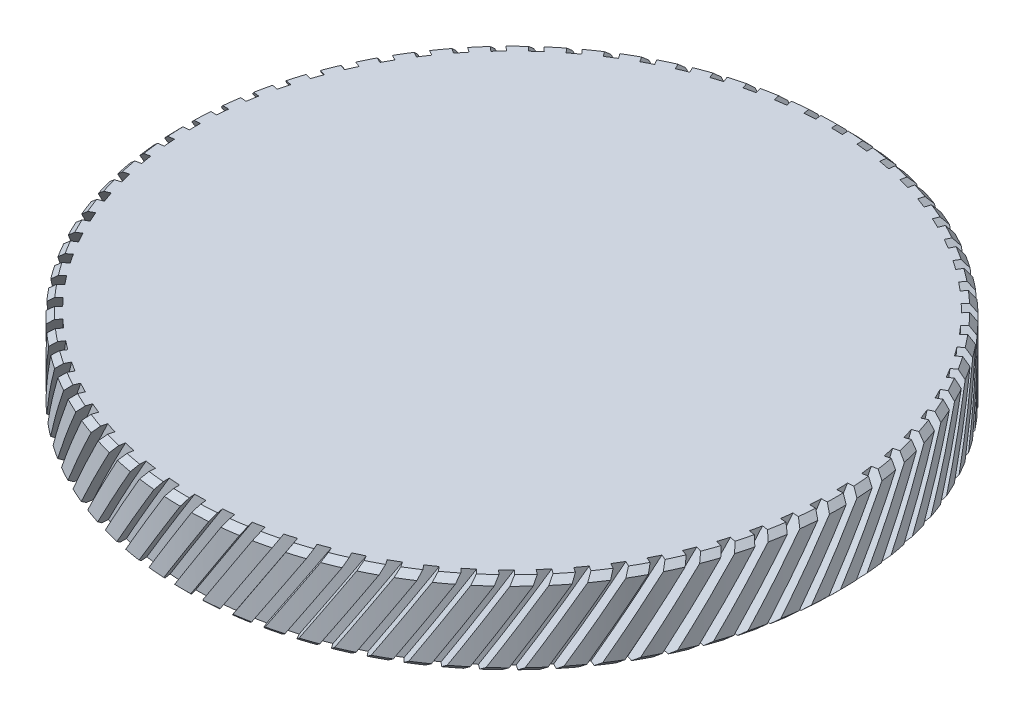
from build123d import *

# Parameters (mm, degrees)
CHAMFER_1_SIZE           = 0.5
CUT_EXTRUDE_1_REACH      = 73.782
CUT_EXTRUDE_1_END_RADIUS = 27
CUT_EXTRUDE_START        = 30
PATTERN_CIRCULAR_1_COUNT = 75


with BuildPart() as part:
    # 草图1 → 旋转1 (revolve)
    with BuildSketch(Plane.XY, mode=Mode.PRIVATE) as revolve_1_sk:
        Polygon((25.1, -8.830884482), (26.1, -8.830884482), (26.1, -7.830884482), (0, -7.830884482), (0, -6.330884482), (28, -6.330884482), (28, -13.330884482), (25.1, -13.330884482), align=None)
    revolve(revolve_1_sk.sketch.rotate(Axis((0, 46.02073106, 0), (0, -1, 0)), 90), axis=Axis((0, 46.02073106, 0), (0, -1, 0)))

    # 倒角1
    chamfer_1_edges = [part.edges().sort_by_distance(p)[0] for p in [
        (0, -6.330884482, -28),
        (0, -13.330884482, -28),
    ]]
    chamfer(chamfer_1_edges, length=CHAMFER_1_SIZE)

    # 切除-拉伸1: up to this cylinder (the profile starts outside it)
    cut_extrude_1_end = Plane(origin=(0, -8.265312, 0), z_dir=(0, 1, 0)) * Cylinder(CUT_EXTRUDE_1_END_RADIUS, 202.564, mode=Mode.PRIVATE)
    # 草图2 → 切除-拉伸1 (cut, up to the surface)
    with BuildSketch(Plane.XY.offset(CUT_EXTRUDE_START), mode=Mode.PRIVATE) as cut_extrude_1_sk1:
        Polygon((0, -2.775948505), (-6.592317224, -13.330884482), (-5.913788084, -13.754674768), (0.67852914, -3.199738791), align=None)
    cut_extrude_1_tool1 = extrude(cut_extrude_1_sk1.sketch, amount=-CUT_EXTRUDE_1_REACH, mode=Mode.PRIVATE) - cut_extrude_1_end
    cut_extrude_1 = cut_extrude_1_tool1.solids().sort_by_distance((-2.956894, -8.265312, 30))[0]
    add(cut_extrude_1, mode=Mode.SUBTRACT)

    # 阵列(圆周)1: 切除-拉伸1 ×75 about axis
    pattern_circular_1_axis = Axis((0, 0, 0), (0, 1, 0))
    for i in range(1, PATTERN_CIRCULAR_1_COUNT):
        add(cut_extrude_1.rotate(pattern_circular_1_axis, i * 360 / PATTERN_CIRCULAR_1_COUNT), mode=Mode.SUBTRACT)


solid = part.part
